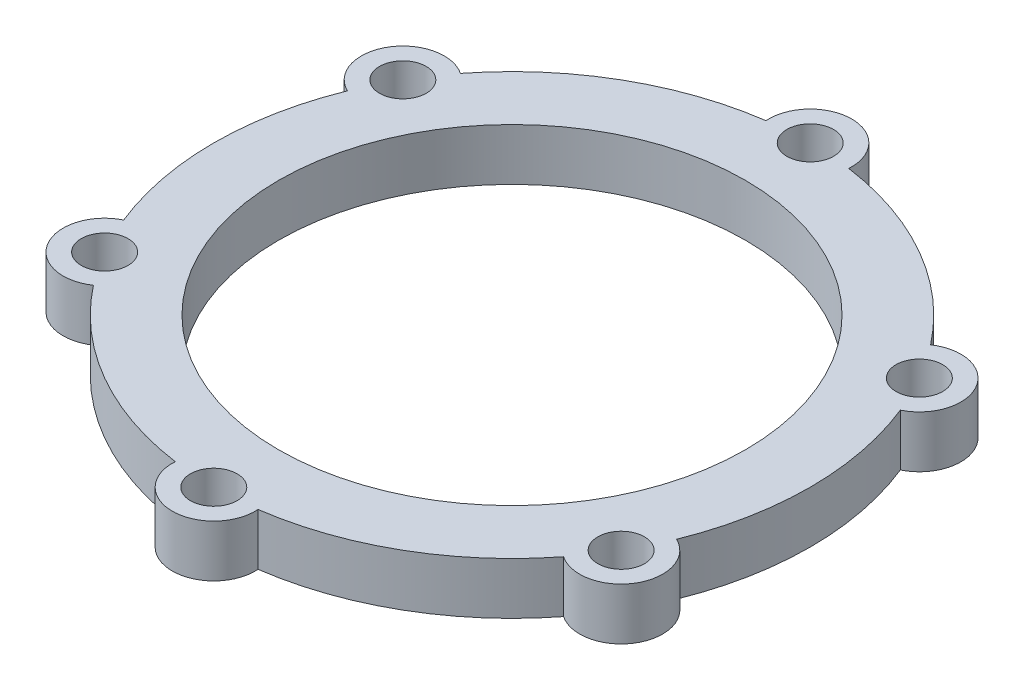
from build123d import *

# Parameters (mm, degrees)
SKETCH1_R           = 45
SKETCH1_R_2         = 4.5
BOSS_EXTRUDE1_DEPTH = 10


with BuildPart() as part:
    # Sketch1 → Boss-Extrude1 (new body)
    with BuildSketch(Plane(origin=(0, 0, 0), x_dir=(1, 0, 0), z_dir=(0, 1, 0))):
        with BuildLine():
            ThreePointArc((-7.980619246, 56.943478261), (-28.75, 49.796460718), (-45.324189131, 35.383158136))
            ThreePointArc((-45.324189131, 35.383158136), (-56.724663948, 32.75), (-53.304808377, 21.560320125))
            ThreePointArc((-53.304808377, 21.560320125), (-57.5, 0), (-53.304808377, -21.560320125))
            ThreePointArc((-53.304808377, -21.560320125), (-56.724663948, -32.75), (-45.324189131, -35.383158136))
            ThreePointArc((-45.324189131, -35.383158136), (-28.75, -49.796460718), (-7.980619246, -56.943478261))
            ThreePointArc((-7.980619246, -56.943478261), (0, -65.5), (7.980619246, -56.943478261))
            ThreePointArc((7.980619246, -56.943478261), (28.75, -49.796460718), (45.324189131, -35.383158136))
            ThreePointArc((45.324189131, -35.383158136), (56.724663948, -32.75), (53.304808377, -21.560320125))
            ThreePointArc((53.304808377, -21.560320125), (57.5, 0), (53.304808377, 21.560320125))
            ThreePointArc((53.304808377, 21.560320125), (56.724663948, 32.75), (45.324189131, 35.383158136))
            ThreePointArc((45.324189131, 35.383158136), (28.75, 49.796460718), (7.980619246, 56.943478261))
            ThreePointArc((7.980619246, 56.943478261), (0, 65.5), (-7.980619246, 56.943478261))
        make_face()
        Circle(SKETCH1_R, mode=Mode.SUBTRACT)
        with Locations((0, 57.5)):
            Circle(SKETCH1_R_2, mode=Mode.SUBTRACT)
        with Locations((49.796460718, 28.75)):
            Circle(SKETCH1_R_2, mode=Mode.SUBTRACT)
        with Locations((49.796460718, -28.75)):
            Circle(SKETCH1_R_2, mode=Mode.SUBTRACT)
        with Locations((0, -57.5)):
            Circle(SKETCH1_R_2, mode=Mode.SUBTRACT)
        with Locations((-49.796460718, -28.75)):
            Circle(SKETCH1_R_2, mode=Mode.SUBTRACT)
        with Locations((-49.796460718, 28.75)):
            Circle(SKETCH1_R_2, mode=Mode.SUBTRACT)
    extrude(amount=BOSS_EXTRUDE1_DEPTH)


solid = part.part
